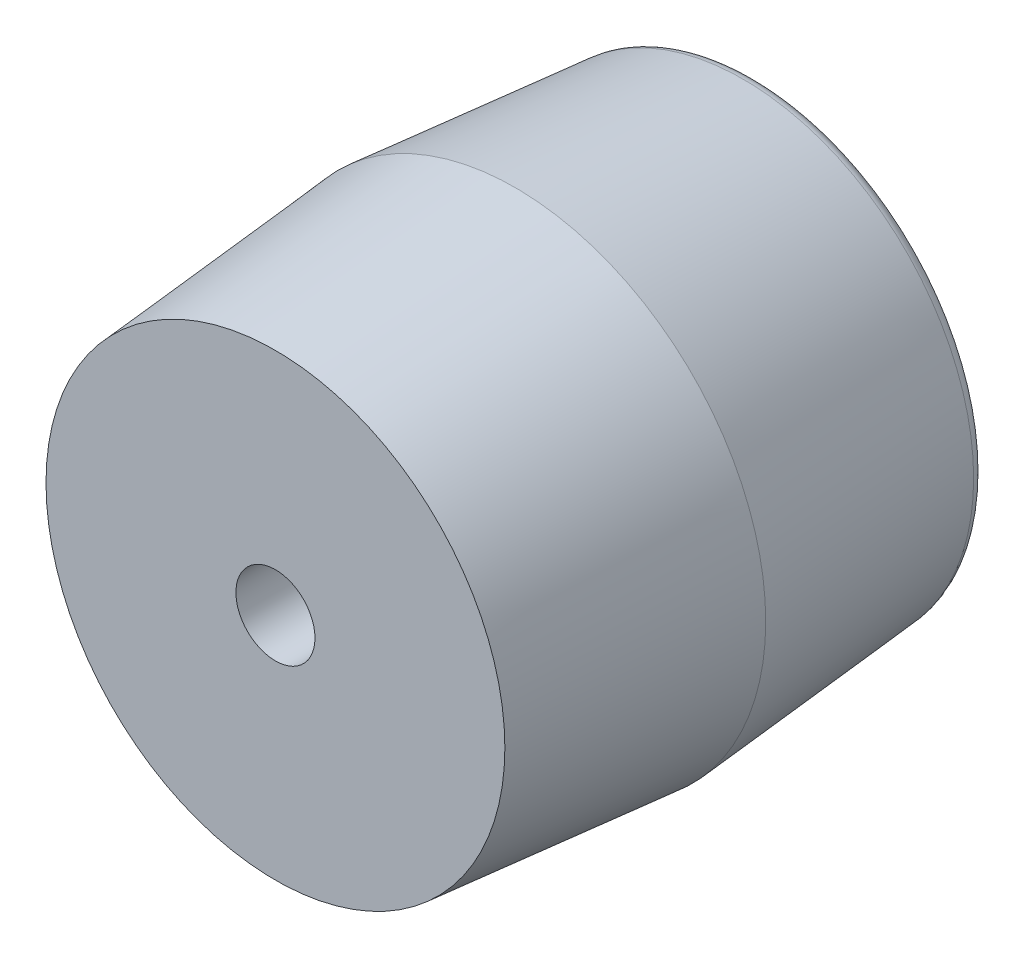
from build123d import *

# Parameters (mm, degrees)
SKETCH1_R                     = 9.5
BOSS_EXTRUDE1_DEPTH           = 9.1
BOSS_EXTRUDE1_TAPER           = 5
BOSS_EXTRUDE1_OTHER_WAY_DEPTH = 9.1
BOSS_EXTRUDE1_OTHER_WAY_TAPER = 5
FILLET1_R                     = 0.5
SKETCH2_R                     = 1.5
CUT_EXTRUDE1_DEPTH            = 18.5


with BuildPart() as part:
    # Sketch1 → Boss-Extrude1 (new body)
    with BuildSketch(Plane.XY):
        Circle(SKETCH1_R)
    extrude(amount=BOSS_EXTRUDE1_DEPTH, taper=BOSS_EXTRUDE1_TAPER)

    # Sketch1 → Boss-Extrude1 other way (add)
    with BuildSketch(Plane.XY):
        Circle(SKETCH1_R)
    extrude(amount=-BOSS_EXTRUDE1_OTHER_WAY_DEPTH, taper=BOSS_EXTRUDE1_OTHER_WAY_TAPER)

    # Fillet1
    fillet1_edges = [part.edges().sort_by_distance(p)[0] for p in [
        (-8.703853162, 0, -9.1),
    ]]
    fillet(fillet1_edges, radius=FILLET1_R)

    # Sketch2 → Cut-Extrude1 (cut)
    with BuildSketch(Plane.XY.offset(9.1)):
        Circle(SKETCH2_R)
    extrude(amount=-CUT_EXTRUDE1_DEPTH, mode=Mode.SUBTRACT)


solid = part.part
